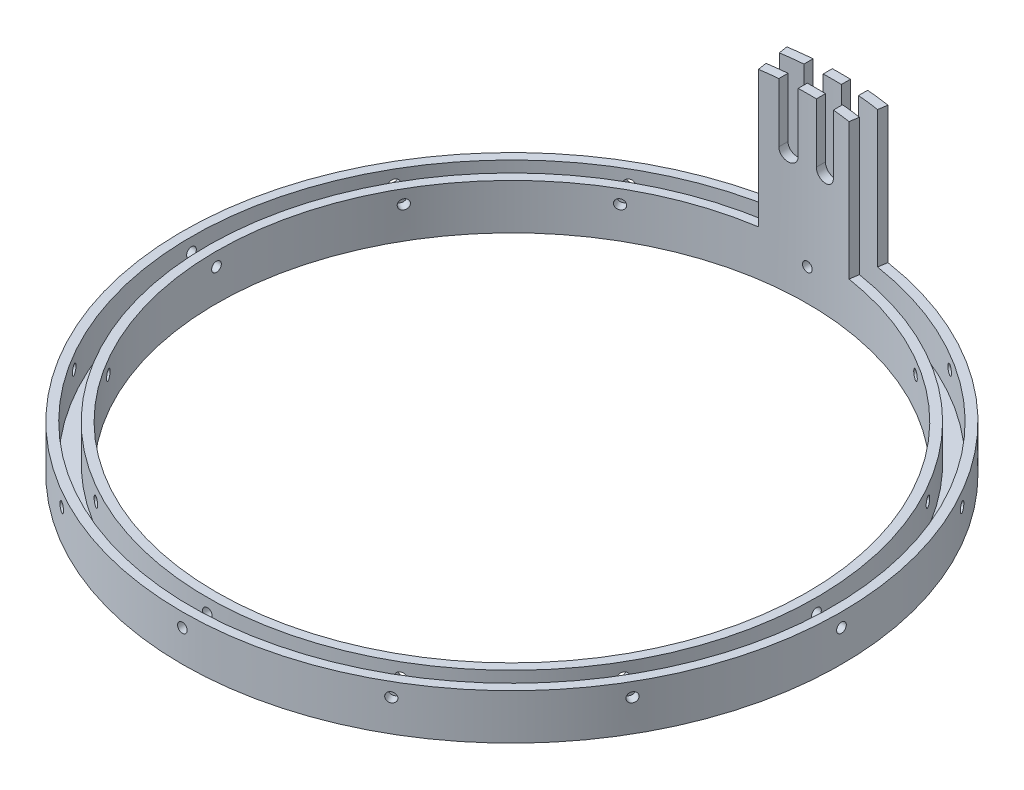
from build123d import *

# Parameters (mm, degrees)
SKETCH1_R               = 92.075
SKETCH1_R_2             = 82.55
BOSS_EXTRUDE1_DEPTH     = 12.7
CUT_EXTRUDE2_START      = -92.075
SKETCH3_R               = 1.35255
CUT_EXTRUDE2_DEPTH      = 9.536081
CIRPATTERN1_COUNT       = 12
BOSS_EXTRUDE2_DEPTH     = 38.1
SKETCH2_R               = 89.535
SKETCH2_R_2             = 85.09
CUT_EXTRUDE1_DEPTH      = 38.1
CUT_EXTRUDE1_DEPTH_BACK = 10.16
CUT_EXTRUDE3_START      = -92.039959
CUT_EXTRUDE3_DEPTH      = 177.129959


with BuildPart() as part:
    # Sketch1 → Boss-Extrude1 (new body)
    with BuildSketch(Plane(origin=(0, 0, 0), x_dir=(1, 0, 0), z_dir=(0, 1, 0))):
        Circle(SKETCH1_R)
        Circle(SKETCH1_R_2, mode=Mode.SUBTRACT)
    extrude(amount=BOSS_EXTRUDE1_DEPTH)

    # Sketch3 → Cut-Extrude2 (cut)
    with BuildSketch(Plane.XY.offset(CUT_EXTRUDE2_START)):
        with Locations((0, 8.89)):
            Circle(SKETCH3_R)
    cut_extrude2 = extrude(amount=CUT_EXTRUDE2_DEPTH, mode=Mode.SUBTRACT)

    # CirPattern1: Cut-Extrude2 ×12 about axis
    cirpattern1_axis = Axis((0, 12.7, 0), (0, 1, 0))
    for i in range(1, CIRPATTERN1_COUNT):
        add(cut_extrude2.rotate(cirpattern1_axis, i * 360 / CIRPATTERN1_COUNT), mode=Mode.SUBTRACT)

    # Sketch4 → Boss-Extrude2 (add)
    with BuildSketch(Plane(origin=(0, 12.7, 0), x_dir=(1, 0, 0), z_dir=(0, 1, 0))):
        with BuildLine():
            Line((-12.7, 81.567226875), (-14.165384615, 90.978829975))
            ThreePointArc((-14.165384615, 90.978829975), (-0.056482912, 92.074982675), (14.053753031, 90.996140856))
            Line((14.053753031, 90.996140856), (12.599916511, 81.582746975))
            ThreePointArc((12.599916511, 81.582746975), (-0.050639852, 82.549984468), (-12.7, 81.567226875))
        make_face()
    extrude(amount=BOSS_EXTRUDE2_DEPTH)

    # Sketch2 → Cut-Extrude1 (cut, two sides)
    with BuildSketch(Plane(origin=(0, 12.7, 0), x_dir=(1, 0, 0), z_dir=(0, 1, 0))) as cut_extrude1_sk:
        Circle(SKETCH2_R)
        Circle(SKETCH2_R_2, mode=Mode.SUBTRACT)
    extrude(amount=CUT_EXTRUDE1_DEPTH, mode=Mode.SUBTRACT)
    extrude(cut_extrude1_sk.sketch, amount=-CUT_EXTRUDE1_DEPTH_BACK, mode=Mode.SUBTRACT)

    # Sketch6 → Cut-Extrude3 (cut)
    with BuildSketch(Plane.XY.offset(CUT_EXTRUDE3_START)):
        with BuildLine():
            Line((7.62, 59.69), (7.62, 34.29))
            ThreePointArc((7.62, 34.29), (5.08, 31.75), (2.54, 34.29))
            Line((2.54, 34.29), (2.54, 59.69))
            ThreePointArc((2.54, 59.69), (5.08, 62.23), (7.62, 59.69))
        make_face()
        with BuildLine():
            Line((-2.54, 59.69), (-2.54, 34.29))
            ThreePointArc((-2.54, 34.29), (-5.08, 31.75), (-7.62, 34.29))
            Line((-7.62, 34.29), (-7.62, 59.69))
            ThreePointArc((-7.62, 59.69), (-5.08, 62.23), (-2.54, 59.69))
        make_face()
    extrude(amount=CUT_EXTRUDE3_DEPTH, mode=Mode.SUBTRACT)


solid = part.part
